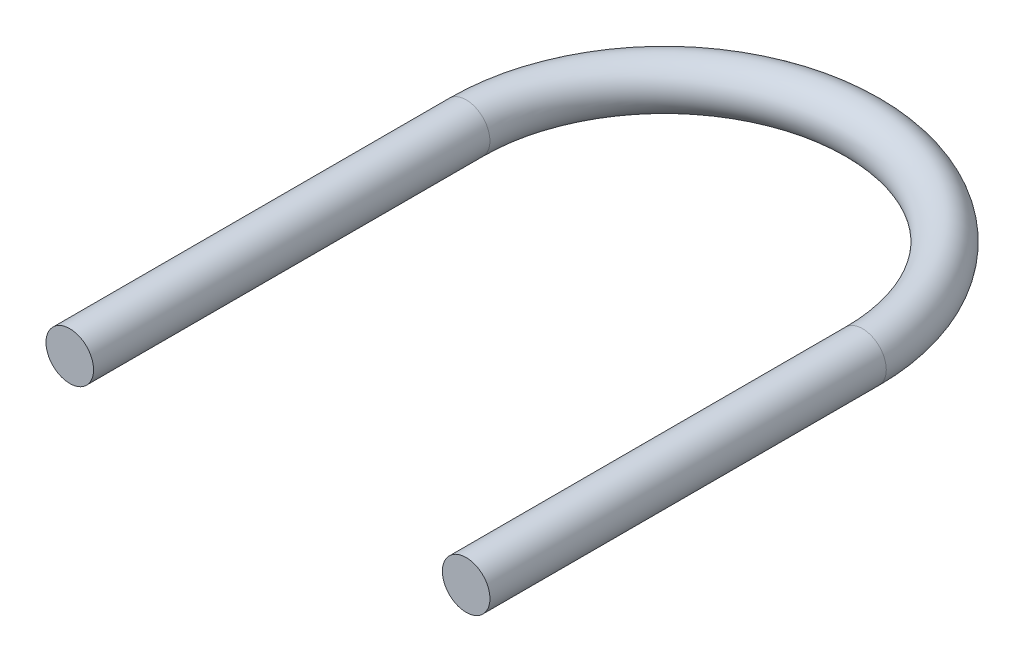
from build123d import *

# Parameters (mm, degrees)
SZKIC2_R = 3


with BuildPart() as part:
    # Wyciągnięcie po ścieżce1: sweep along a path in Szkic1
    with BuildLine(Plane(origin=(0, 0, 0), x_dir=(1, 0, 0), z_dir=(0, 1, 0))) as wyci_gni_cie_po_cie_ce1_path:
        Line((-25, -50), (-25, 0))
        ThreePointArc((-25, 0), (0, 25), (25, 0))
        Line((25, 0), (25, -50))
    # Szkic2 → Wyciągnięcie po ścieżce1 (sweep)
    with BuildSketch(Plane.XY.offset(50)):
        with Locations((-25, 0)):
            Circle(SZKIC2_R)
    sweep(path=wyci_gni_cie_po_cie_ce1_path.line)


solid = part.part
